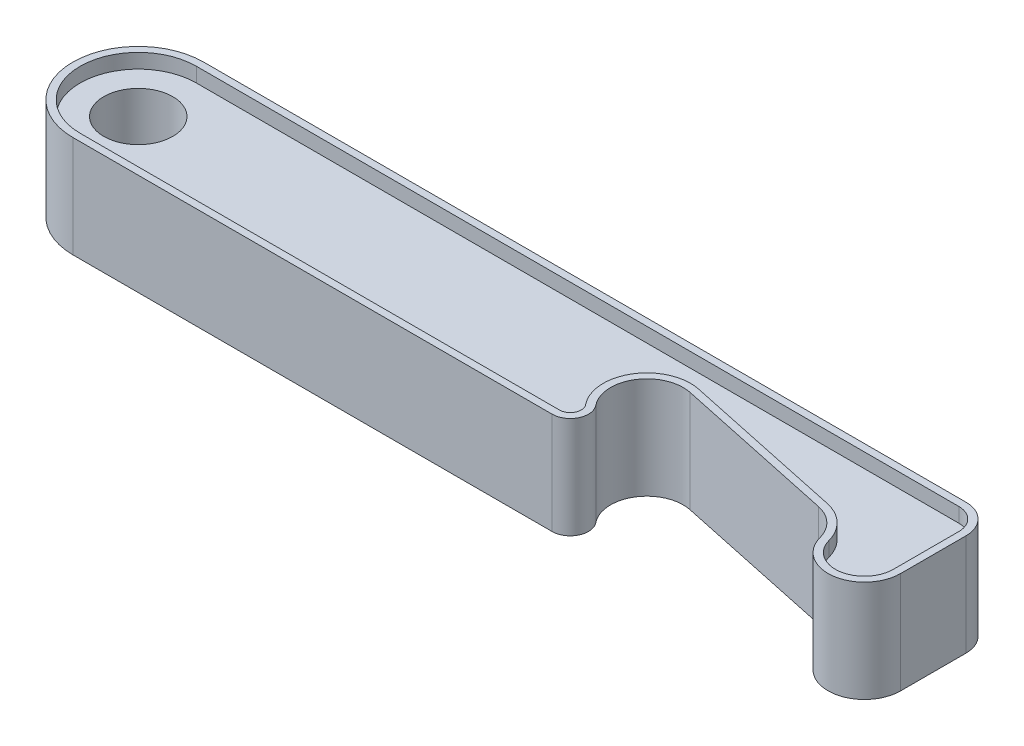
from build123d import *

# Parameters (mm, degrees)
SKETCH1_R           = 4.75
BOSS_EXTRUDE1_DEPTH = 14
CUT_EXTRUDE1_DEPTH  = 2
CUT_EXTRUDE2_DEPTH  = 2


with BuildPart() as part:
    # Sketch1 → Boss-Extrude1 (new body)
    with BuildSketch(Plane(origin=(0, 0, 0), x_dir=(1, 0, 0), z_dir=(0, 1, 0))):
        with BuildLine():
            Line((0, 9), (105, 9))
            ThreePointArc((105, 9), (107.828427125, 7.828427125), (109, 5))
            Line((109, 5), (109, -4))
            ThreePointArc((109, -4), (104.648590849, -8.957754523), (99.168268036, -5.286221686))
            ThreePointArc((99.168268036, -5.286221686), (97.78126353, -2.948377598), (95.376094526, -1.681705369))
            Line((95.376094526, -1.681705369), (72.876094526, 3.100817269))
            ThreePointArc((72.876094526, 3.100817269), (67.575536844, 0.826161371), (67.945512024, -4.929973578))
            ThreePointArc((67.945512024, -4.929973578), (68.255556035, -7.578177617), (66, -9))
            Line((66, -9), (0, -9))
            ThreePointArc((0, -9), (-9, 0), (0, 9))
        make_face()
        Circle(SKETCH1_R, mode=Mode.SUBTRACT)
    extrude(amount=BOSS_EXTRUDE1_DEPTH)

    # Sketch4 → Cut-Extrude1 (cut)
    with BuildSketch(Plane(origin=(0, 14, 0), x_dir=(1, 0, 0), z_dir=(0, 1, 0))):
        with BuildLine():
            Line((0, -8), (66, -8))
            ThreePointArc((66, -8), (67.353333621, -7.14690657), (67.167307214, -5.557984147))
            ThreePointArc((67.167307214, -5.557984147), (66.723336999, 1.349377792), (73.084006216, 4.07896487))
            Line((73.084006216, 4.07896487), (95.584006216, -0.703557768))
            ThreePointArc((95.584006216, -0.703557768), (98.470209022, -2.223564443), (100.134614429, -5.028977349))
            ThreePointArc((100.134614429, -5.028977349), (104.518872679, -7.966203618), (108, -4))
            Line((108, -4), (108, 5))
            ThreePointArc((108, 5), (107.121320344, 7.121320344), (105, 8))
            Line((105, 8), (0, 8))
            ThreePointArc((0, 8), (-8, 0), (0, -8))
        make_face()
    extrude(amount=-CUT_EXTRUDE1_DEPTH, mode=Mode.SUBTRACT)

    # Sketch5 → Cut-Extrude2 (cut)
    with BuildSketch(Plane.XZ):
        with BuildLine():
            Line((0, -8), (105, -8))
            ThreePointArc((105, -8), (107.121320344, -7.121320344), (108, -5))
            Line((108, -5), (108, 4))
            ThreePointArc((108, 4), (104.518872679, 7.966203618), (100.134614429, 5.028977349))
            ThreePointArc((100.134614429, 5.028977349), (98.470209022, 2.223564443), (95.584006216, 0.703557768))
            Line((95.584006216, 0.703557768), (73.084006216, -4.07896487))
            ThreePointArc((73.084006216, -4.07896487), (66.723336999, -1.349377792), (67.167307214, 5.557984147))
            ThreePointArc((67.167307214, 5.557984147), (67.353333621, 7.14690657), (66, 8))
            Line((66, 8), (0, 8))
            ThreePointArc((0, 8), (-8, 0), (0, -8))
        make_face()
    extrude(amount=-CUT_EXTRUDE2_DEPTH, mode=Mode.SUBTRACT)


solid = part.part
